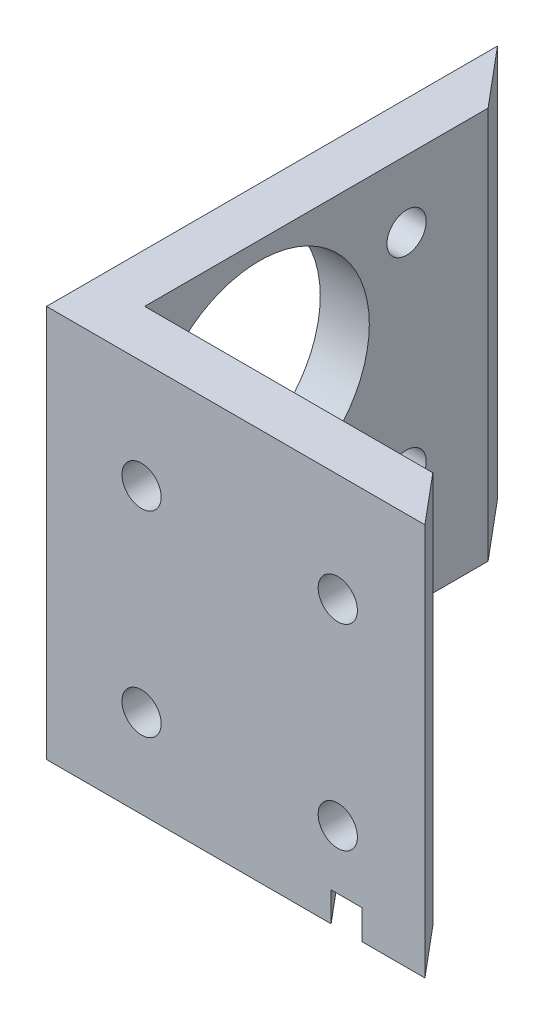
from build123d import *

# Parameters (mm, degrees)
BOSS_EXTRUDE1_DEPTH = 50.8
CUT_EXTRUDE2_REACH  = 8.35
SKETCH4_R           = 2.54
CUT_EXTRUDE1_REACH  = 8.35
SKETCH3_R           = 2.54
SKETCH3_R_2         = 14.224
CUT_EXTRUDE3_DEPTH  = 3.81


with BuildPart() as part:
    # Sketch2 → Boss-Extrude1 (new body)
    with BuildSketch(Plane(origin=(0, 0, 0), x_dir=(1, 0, 0), z_dir=(0, 1, 0))):
        Polygon((0, 58.372586566), (0, 0), (48.980415858, 0), (43.6521332, 6.35), (6.35, 6.35), (6.35, 50.804951253), align=None)
    extrude(amount=BOSS_EXTRUDE1_DEPTH)

    # Sketch4 → Cut-Extrude2 (cut, up to next)
    with BuildSketch(Plane(origin=(0, 0, -6.35), x_dir=(-1, 0, 0), z_dir=(0, 0, -1)), mode=Mode.PRIVATE) as cut_extrude2_sk1:
        with Locations((-37.7010666, 36.83)):
            Circle(SKETCH4_R)
    cut_extrude2_tool1 = extrude(cut_extrude2_sk1.sketch, amount=-CUT_EXTRUDE2_REACH, mode=Mode.PRIVATE) & part.part
    add(cut_extrude2_tool1.solids().sort_by_distance((37.701067, 36.83, -6.35))[0], mode=Mode.SUBTRACT)
    # Sketch4 → Cut-Extrude2 (cut, up to next)
    with BuildSketch(Plane(origin=(0, 0, -6.35), x_dir=(-1, 0, 0), z_dir=(0, 0, -1)), mode=Mode.PRIVATE) as cut_extrude2_sk2:
        with Locations((-12.3010666, 36.83)):
            Circle(SKETCH4_R)
    cut_extrude2_tool2 = extrude(cut_extrude2_sk2.sketch, amount=-CUT_EXTRUDE2_REACH, mode=Mode.PRIVATE) & part.part
    add(cut_extrude2_tool2.solids().sort_by_distance((12.301067, 36.83, -6.35))[0], mode=Mode.SUBTRACT)
    # Sketch4 → Cut-Extrude2 (cut, up to next)
    with BuildSketch(Plane(origin=(0, 0, -6.35), x_dir=(-1, 0, 0), z_dir=(0, 0, -1)), mode=Mode.PRIVATE) as cut_extrude2_sk3:
        with Locations((-37.7010666, 11.43)):
            Circle(SKETCH4_R)
    cut_extrude2_tool3 = extrude(cut_extrude2_sk3.sketch, amount=-CUT_EXTRUDE2_REACH, mode=Mode.PRIVATE) & part.part
    add(cut_extrude2_tool3.solids().sort_by_distance((37.701067, 11.43, -6.35))[0], mode=Mode.SUBTRACT)
    # Sketch4 → Cut-Extrude2 (cut, up to next)
    with BuildSketch(Plane(origin=(0, 0, -6.35), x_dir=(-1, 0, 0), z_dir=(0, 0, -1)), mode=Mode.PRIVATE) as cut_extrude2_sk4:
        with Locations((-12.3010666, 11.43)):
            Circle(SKETCH4_R)
    cut_extrude2_tool4 = extrude(cut_extrude2_sk4.sketch, amount=-CUT_EXTRUDE2_REACH, mode=Mode.PRIVATE) & part.part
    add(cut_extrude2_tool4.solids().sort_by_distance((12.301067, 11.43, -6.35))[0], mode=Mode.SUBTRACT)

    # Sketch3 → Cut-Extrude1 (cut, up to next)
    with BuildSketch(Plane(origin=(6.35, 0, 0), x_dir=(0, 0, -1), z_dir=(1, 0, 0)), mode=Mode.PRIVATE) as cut_extrude1_sk1:
        with Locations((13.335, 15.2019)):
            Circle(SKETCH3_R)
    cut_extrude1_tool1 = extrude(cut_extrude1_sk1.sketch, amount=-CUT_EXTRUDE1_REACH, mode=Mode.PRIVATE) & part.part
    add(cut_extrude1_tool1.solids().sort_by_distance((6.35, 15.2019, -13.335))[0], mode=Mode.SUBTRACT)
    # Sketch3 → Cut-Extrude1 (cut, up to next)
    with BuildSketch(Plane(origin=(6.35, 0, 0), x_dir=(0, 0, -1), z_dir=(1, 0, 0)), mode=Mode.PRIVATE) as cut_extrude1_sk2:
        with Locations((21.209, 34.2519)):
            Circle(SKETCH3_R_2)
    cut_extrude1_tool2 = extrude(cut_extrude1_sk2.sketch, amount=-CUT_EXTRUDE1_REACH, mode=Mode.PRIVATE) & part.part
    add(cut_extrude1_tool2.solids().sort_by_distance((6.35, 34.2519, -21.209))[0], mode=Mode.SUBTRACT)
    # Sketch3 → Cut-Extrude1 (cut, up to next)
    with BuildSketch(Plane(origin=(6.35, 0, 0), x_dir=(0, 0, -1), z_dir=(1, 0, 0)), mode=Mode.PRIVATE) as cut_extrude1_sk3:
        with Locations((40.259, 15.2019)):
            Circle(SKETCH3_R)
    cut_extrude1_tool3 = extrude(cut_extrude1_sk3.sketch, amount=-CUT_EXTRUDE1_REACH, mode=Mode.PRIVATE) & part.part
    add(cut_extrude1_tool3.solids().sort_by_distance((6.35, 15.2019, -40.259))[0], mode=Mode.SUBTRACT)
    # Sketch3 → Cut-Extrude1 (cut, up to next)
    with BuildSketch(Plane(origin=(6.35, 0, 0), x_dir=(0, 0, -1), z_dir=(1, 0, 0)), mode=Mode.PRIVATE) as cut_extrude1_sk4:
        with Locations((40.259, 42.1259)):
            Circle(SKETCH3_R)
    cut_extrude1_tool4 = extrude(cut_extrude1_sk4.sketch, amount=-CUT_EXTRUDE1_REACH, mode=Mode.PRIVATE) & part.part
    add(cut_extrude1_tool4.solids().sort_by_distance((6.35, 42.1259, -40.259))[0], mode=Mode.SUBTRACT)

    # Sketch5 → Cut-Extrude3 (cut)
    with BuildSketch(Plane.XZ):
        Polygon((0, -48.643822138), (40.817013215, 0), (36.838131797, 0), (0, -43.901975914), align=None)
    extrude(amount=-CUT_EXTRUDE3_DEPTH, mode=Mode.SUBTRACT)


solid = part.part
